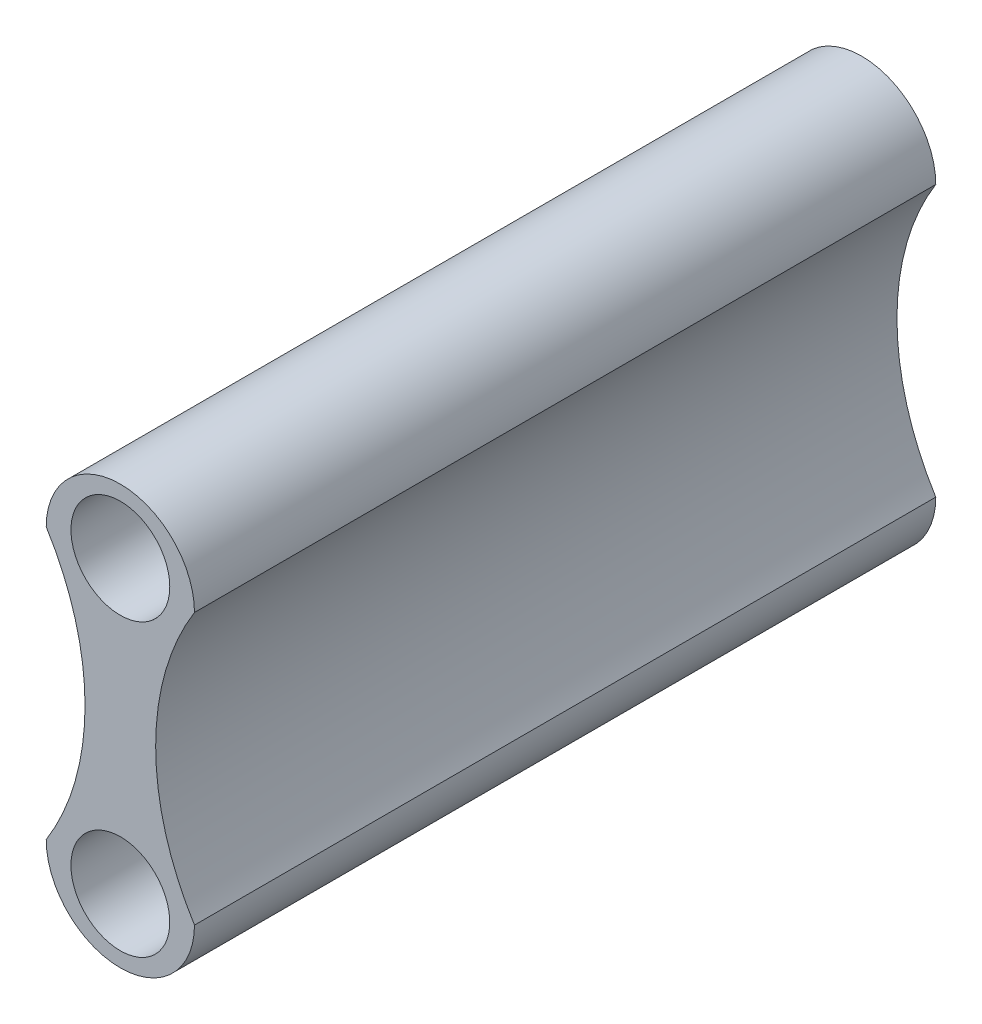
from build123d import *

# Parameters (mm, degrees)
BOSS_EXTRUDE1_DEPTH = 15
SKETCH2_R           = 1
CUT_EXTRUDE1_DEPTH  = 4
SKETCH3_R           = 1
CUT_EXTRUDE2_DEPTH  = 4


with BuildPart() as part:
    # Sketch1 → Boss-Extrude1 (new body)
    with BuildSketch(Plane.XY):
        with BuildLine():
            ThreePointArc((1.5, 0), (0, 1.5), (-1.5, 0))
            ThreePointArc((-1.5, 0), (-0.714591942, -2.739389257), (-1.5, -5.478778514))
            ThreePointArc((-1.5, -5.478778514), (0, -6.978778514), (1.5, -5.478778514))
            ThreePointArc((1.5, -5.478778514), (0.714591942, -2.739389257), (1.5, 0))
        make_face()
    extrude(amount=BOSS_EXTRUDE1_DEPTH)

    # Sketch2 → Cut-Extrude1 (cut)
    with BuildSketch(Plane.XY.offset(15)):
        with Locations((0, 0.2)):
            Circle(SKETCH2_R)
        with Locations((0, -5.678778514)):
            Circle(SKETCH2_R)
    extrude(amount=-CUT_EXTRUDE1_DEPTH, mode=Mode.SUBTRACT)

    # Sketch3 → Cut-Extrude2 (cut)
    with BuildSketch(Plane(origin=(0, 0, 0), x_dir=(-1, 0, 0), z_dir=(0, 0, -1))):
        with Locations((0, 0.2)):
            Circle(SKETCH3_R)
        with Locations((0, -5.678778514)):
            Circle(SKETCH3_R)
    extrude(amount=-CUT_EXTRUDE2_DEPTH, mode=Mode.SUBTRACT)


solid = part.part
